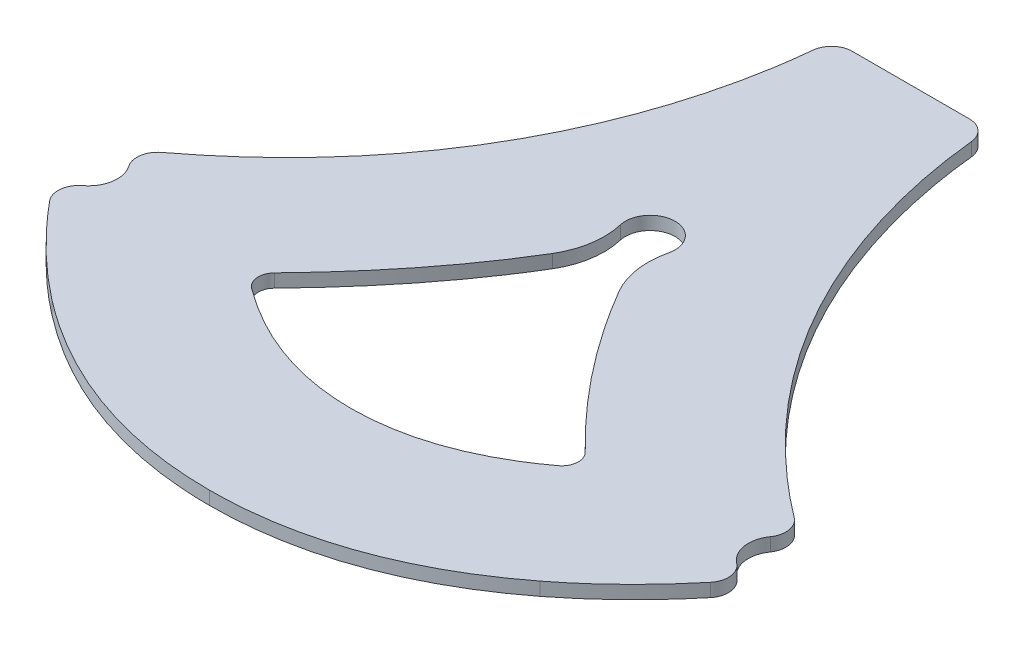
from build123d import *

# Parameters (mm, degrees)
BOSS_EXTRUDE1_DEPTH = 1.6


with BuildPart() as part:
    # Sketch1 → Boss-Extrude1 (new body)
    with BuildSketch(Plane(origin=(0, -12.08184695, 0), x_dir=(1, 0, 0), z_dir=(0, 1, 0))):
        with BuildLine():
            Line((7.068263687, 41.600601737), (-7.059496612, 41.600601737))
            ThreePointArc((-7.059496612, 41.600601737), (-8.738121808, 40.953226214), (-9.547386312, 39.346375699))
            add(Edge.make_bspline(
                [(-9.547386312, 39.346375699), (-9.791801042, 36.872209768), (-10.174780597, 34.427308106), (-11.191257392, 29.590412993), (-11.825986881, 27.198679788), (-13.350641046, 22.469109457), (-14.231234092, 20.161687267), (-16.219413971, 15.670679569), (-17.327255507, 13.484910955), (-19.77160384, 9.233454443), (-21.107913128, 7.167662826), (-23.287017843, 4.160685833), (-24.044102201, 3.171933948), (-25.600832941, 1.24516113), (-26.401965146, 0.30483539), (-30.518180843, -4.284811803), (-34.16377144, -7.599360565), (-38.1299904, -10.589142877)],
                knots=[0, 0, 0, 0, 0.125, 0.125, 0.25, 0.25, 0.375, 0.375, 0.5, 0.5, 0.625, 0.625, 0.6875, 0.6875, 0.75, 0.75, 1, 1, 1, 1], degree=3))
            ThreePointArc((-38.1299904, -10.589142877), (-39.094420308, -12.194619809), (-38.673009405, -14.019474345))
            ThreePointArc((-38.673009405, -14.019474345), (-38.081769626, -16.566513233), (-39.42061036, -18.812503006))
            ThreePointArc((-39.42061036, -18.812503006), (-40.390492541, -20.517035077), (-39.831968266, -22.396969027))
            add(Edge.make_bspline(
                [(-39.831968266, -22.396969027), (-38.283172708, -24.266437753), (-36.643071519, -26.058655413), (-33.174318098, -29.455880725), (-31.352030623, -31.054807711), (-29.43071323, -32.539448808)],
                knots=[0, 0, 0, 0, 0.5, 0.5, 1, 1, 1, 1], degree=3))
            add(Edge.make_bspline(
                [(-29.43071323, -32.539448808), (-27.320643605, -34.16992841), (-25.110907511, -35.649716155), (-20.460386406, -38.259954595), (-18.045119378, -39.375356082), (-14.281591244, -40.731351728), (-13.014141837, -41.126537478), (-10.462616624, -41.801653768), (-9.177088412, -42.082104136), (-5.291542564, -42.754094477), (-2.662588178, -42.976416738), (0.004383999, -42.976416738)],
                knots=[0, 0, 0, 0, 0.25, 0.25, 0.5, 0.5, 0.625, 0.625, 0.75, 0.75, 1, 1, 1, 1], degree=3))
            add(Edge.make_bspline(
                [(0.004383999, -42.976416738), (2.671656674, -42.976416738), (5.319285582, -42.754113953), (9.259525556, -42.067540092), (10.556225677, -41.781619701), (13.107012662, -41.101381696), (14.362802441, -40.706759914), (16.836410325, -39.811946458), (18.054248498, -39.311810579), (20.452976989, -38.208815379), (21.635192506, -37.605209835), (25.119535884, -35.649249598), (27.327228533, -34.170936704), (29.435499854, -32.542167102)],
                knots=[0, 0, 0, 0, 0.25, 0.25, 0.375, 0.375, 0.5, 0.5, 0.625, 0.625, 0.75, 0.75, 1, 1, 1, 1], degree=3))
            add(Edge.make_bspline(
                [(29.435499854, -32.542167102), (31.356661411, -31.057999079), (33.183178175, -29.455634698), (36.651766782, -26.058931244), (38.289020033, -24.270113959), (39.837842074, -22.401078618)],
                knots=[0, 0, 0, 0, 0.5, 0.5, 1, 1, 1, 1], degree=3))
            ThreePointArc((39.837842074, -22.401078618), (40.396592097, -20.52122374), (39.426929699, -18.816579853))
            ThreePointArc((39.426929699, -18.816579853), (38.088433126, -16.570796705), (38.67950123, -14.024082445))
            ThreePointArc((38.67950123, -14.024082445), (39.100802356, -12.199274218), (38.136401576, -10.593861236))
            add(Edge.make_bspline(
                [(38.136401576, -10.593861236), (34.168623759, -7.602959081), (30.509352448, -4.27682522), (26.366767099, 0.349726066), (25.563654335, 1.294607123), (24.01416015, 3.216210378), (23.26679186, 4.194046735), (21.106661228, 7.178559095), (19.77567512, 9.236115194), (17.332454935, 13.487332018), (16.22037441, 15.681088283), (14.719864957, 19.076008242), (14.246709963, 20.227996379), (13.365900278, 22.544460809), (12.957352394, 23.710625613), (11.82518653, 27.232396594), (11.194571791, 29.611161178), (10.183276163, 34.430925487), (9.800625177, 36.871434644), (9.556155738, 39.346351897)],
                knots=[0, 0, 0, 0, 0.25, 0.25, 0.3125, 0.3125, 0.375, 0.375, 0.5, 0.5, 0.625, 0.625, 0.6875, 0.6875, 0.75, 0.75, 0.875, 0.875, 1, 1, 1, 1], degree=3))
            ThreePointArc((9.556155738, 39.346351897), (8.746897744, 40.953218184), (7.068263687, 41.600601737))
        make_face()
        with BuildLine():
            ThreePointArc((2.917114338, 9.477212595), (2.756374668, 5.872981189), (3.951101823, 2.468726748))
            add(Edge.make_bspline(
                [(18.704113686, -16.363172993), (17.992145269, -15.660180667), (17.284020826, -14.953500566), (15.898077439, -13.511066303), (15.216988025, -12.778449721), (13.209804316, -10.545981706), (11.922619235, -9.014699706), (8.217020706, -4.29052926), (5.969838206, -0.988031562), (3.951101823, 2.468726748)],
                knots=[0, 0, 0, 0, 0.125, 0.125, 0.25, 0.25, 0.5, 0.5, 1, 1, 1, 1], degree=3))
            ThreePointArc((18.704113686, -16.363172993), (19.293025471, -17.93950559), (18.470275007, -19.407403142))
            add(Edge.make_bspline(
                [(-18.494716896, -19.382200256), (-18.156747928, -19.627153591), (-17.818664146, -19.871886584), (-17.13548839, -20.34790294), (-16.790775019, -20.579912893), (-15.746956693, -21.257369006), (-15.038196301, -21.684285132), (-12.870713002, -22.885961299), (-11.370716058, -23.581511117), (-9.025130071, -24.441385157), (-8.223466165, -24.698129558), (-6.613792479, -25.137565491), (-5.80401834, -25.321234472), (-3.359849379, -25.763841436), (-1.710600897, -25.914327465), (0.793635304, -25.91836178), (1.634808791, -25.88219159), (3.293827112, -25.736118011), (4.115824788, -25.626398759), (6.559865603, -25.190037003), (8.159961985, -24.756217145), (10.518010173, -23.899908948), (11.293937095, -23.580881464), (12.808242427, -22.888006864), (13.549502528, -22.513052805), (15.00267183, -21.710479018), (15.714628815, -21.282945031), (16.762116652, -20.60495391), (17.107865076, -20.372830636), (17.792765058, -19.896747026), (18.131563633, -19.652153318), (18.470275007, -19.407403142)],
                knots=[0, 0, 0, 0, 0.03125, 0.03125, 0.0625, 0.0625, 0.125, 0.125, 0.25, 0.25, 0.3125, 0.3125, 0.375, 0.375, 0.5, 0.5, 0.5625, 0.5625, 0.625, 0.625, 0.75, 0.75, 0.8125, 0.8125, 0.875, 0.875, 0.9375, 0.9375, 0.96875, 0.96875, 1, 1, 1, 1], degree=3))
            ThreePointArc((-18.494716896, -19.382200256), (-19.313315476, -17.938131693), (-18.759498896, -16.373291495))
            add(Edge.make_bspline(
                [(-4.019478984, 2.418815751), (-6.073388857, -1.004555589), (-8.371219964, -4.274194721), (-12.087144101, -8.96897705), (-13.369226154, -10.496572825), (-15.349259798, -12.736872688), (-16.018851728, -13.47516887), (-17.376233604, -14.935672121), (-18.066404983, -15.655773734), (-18.759498896, -16.373291495)],
                knots=[0, 0, 0, 0, 0.5, 0.5, 0.75, 0.75, 0.875, 0.875, 1, 1, 1, 1], degree=3))
            ThreePointArc((-4.019478984, 2.418815751), (-2.778667962, 5.846147783), (-2.919787203, 9.488441319))
            ThreePointArc((-2.919787203, 9.488441319), (0.005771232, 13.17752407), (2.917114338, 9.477212595))
        make_face(mode=Mode.SUBTRACT)
    extrude(amount=BOSS_EXTRUDE1_DEPTH)


solid = part.part
